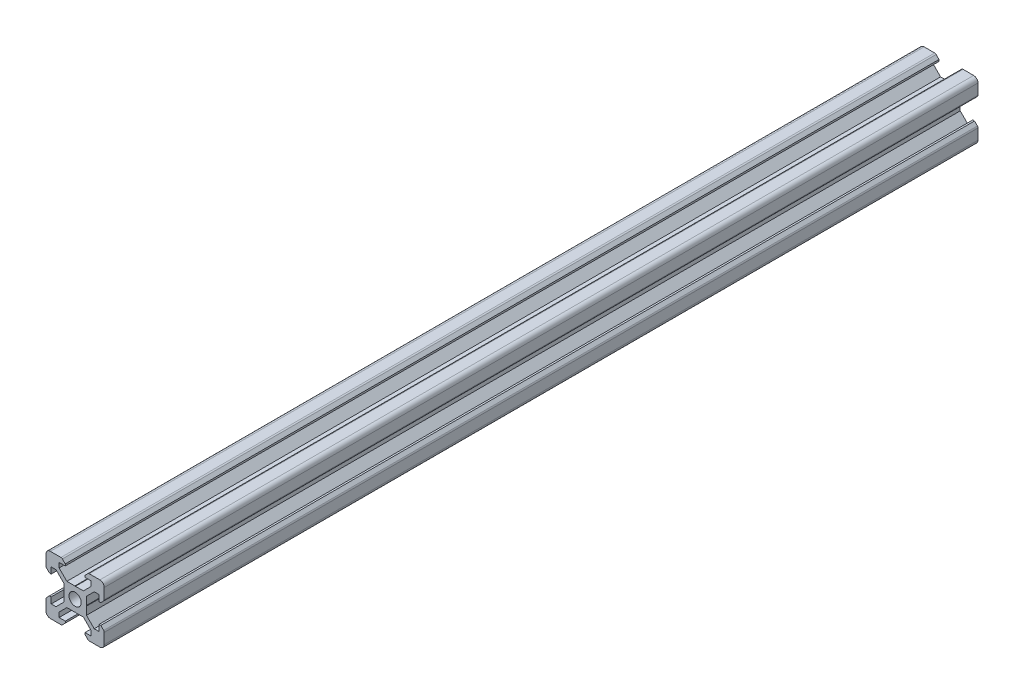
from build123d import *

# Parameters (mm, degrees)
SKETCH1_R           = 2.1
BOSS_EXTRUDE1_DEPTH = 300


with BuildPart() as part:
    # Sketch1 → Boss-Extrude1 (new body)
    with BuildSketch(Plane.XY):
        with BuildLine():
            Line((-8.5, 10), (-4.862792737, 10))
            ThreePointArc((-4.862792737, 10), (-4.598292737, 9.947387679), (-4.374060464, 9.797560464))
            Line((-4.374060464, 9.797560464), (-3.3865, 8.81))
            Line((-3.3865, 8.81), (-3.3865, 8.2))
            Line((-3.3865, 8.2), (-5.5, 8.2))
            Line((-5.5, 8.2), (-5.5, 6.561))
            Line((-5.5, 6.561), (-2.8395, 3.9005))
            Line((-2.8395, 3.9005), (-0.1, 3.9005))
            Line((-0.1, 3.9005), (0, 3.8005))
            Line((0, 3.8005), (0.1, 3.9005))
            Line((0.1, 3.9005), (2.8395, 3.9005))
            Line((2.8395, 3.9005), (5.5, 6.561))
            Line((5.5, 6.561), (5.5, 8.2))
            Line((5.5, 8.2), (3.3865, 8.2))
            Line((3.3865, 8.2), (3.3865, 8.81))
            Line((3.3865, 8.81), (4.374060464, 9.797560464))
            ThreePointArc((4.374060464, 9.797560464), (4.598292737, 9.947387679), (4.862792737, 10))
            Line((4.862792737, 10), (8.5, 10))
            ThreePointArc((8.5, 10), (9.560660172, 9.560660172), (10, 8.5))
            Line((10, 8.5), (10, 4.862792737))
            ThreePointArc((10, 4.862792737), (9.947387679, 4.598292737), (9.797560464, 4.374060464))
            Line((9.797560464, 4.374060464), (8.81, 3.3865))
            Line((8.81, 3.3865), (8.2, 3.3865))
            Line((8.2, 3.3865), (8.2, 5.5))
            Line((8.2, 5.5), (6.561, 5.5))
            Line((6.561, 5.5), (3.9005, 2.8395))
            Line((3.9005, 2.8395), (3.9005, 0.1))
            Line((3.9005, 0.1), (3.8005, 0))
            Line((3.8005, 0), (3.9005, -0.1))
            Line((3.9005, -0.1), (3.9005, -2.8395))
            Line((3.9005, -2.8395), (6.561, -5.5))
            Line((6.561, -5.5), (8.2, -5.5))
            Line((8.2, -5.5), (8.2, -3.3865))
            Line((8.2, -3.3865), (8.81, -3.3865))
            Line((8.81, -3.3865), (9.797560464, -4.374060464))
            ThreePointArc((9.797560464, -4.374060464), (9.947387679, -4.598292737), (10, -4.862792737))
            Line((10, -4.862792737), (10, -8.5))
            ThreePointArc((10, -8.5), (9.560660172, -9.560660172), (8.5, -10))
            Line((8.5, -10), (4.862792737, -10))
            ThreePointArc((4.862792737, -10), (4.598292737, -9.947387679), (4.374060464, -9.797560464))
            Line((4.374060464, -9.797560464), (3.3865, -8.81))
            Line((3.3865, -8.81), (3.3865, -8.2))
            Line((3.3865, -8.2), (5.5, -8.2))
            Line((5.5, -8.2), (5.5, -6.561))
            Line((5.5, -6.561), (2.8395, -3.9005))
            Line((2.8395, -3.9005), (0.1, -3.9005))
            Line((0.1, -3.9005), (0, -3.8005))
            Line((0, -3.8005), (-0.1, -3.9005))
            Line((-0.1, -3.9005), (-2.8395, -3.9005))
            Line((-2.8395, -3.9005), (-5.5, -6.561))
            Line((-5.5, -6.561), (-5.5, -8.2))
            Line((-5.5, -8.2), (-3.3865, -8.2))
            Line((-3.3865, -8.2), (-3.3865, -8.81))
            Line((-3.3865, -8.81), (-4.374060464, -9.797560464))
            ThreePointArc((-4.374060464, -9.797560464), (-4.598292737, -9.947387679), (-4.862792737, -10))
            Line((-4.862792737, -10), (-8.5, -10))
            ThreePointArc((-8.5, -10), (-9.560660172, -9.560660172), (-10, -8.5))
            Line((-10, -8.5), (-10, -4.862792737))
            ThreePointArc((-10, -4.862792737), (-9.947387679, -4.598292737), (-9.797560464, -4.374060464))
            Line((-9.797560464, -4.374060464), (-8.81, -3.3865))
            Line((-8.81, -3.3865), (-8.2, -3.3865))
            Line((-8.2, -3.3865), (-8.2, -5.5))
            Line((-8.2, -5.5), (-6.561, -5.5))
            Line((-6.561, -5.5), (-3.9005, -2.8395))
            Line((-3.9005, -2.8395), (-3.9005, -0.1))
            Line((-3.9005, -0.1), (-3.8005, 0))
            Line((-3.8005, 0), (-3.9005, 0.1))
            Line((-3.9005, 0.1), (-3.9005, 2.8395))
            Line((-3.9005, 2.8395), (-6.561, 5.5))
            Line((-6.561, 5.5), (-8.2, 5.5))
            Line((-8.2, 5.5), (-8.2, 3.3865))
            Line((-8.2, 3.3865), (-8.81, 3.3865))
            Line((-8.81, 3.3865), (-9.797560464, 4.374060464))
            ThreePointArc((-9.797560464, 4.374060464), (-9.947387679, 4.598292737), (-10, 4.862792737))
            Line((-10, 4.862792737), (-10, 8.5))
            ThreePointArc((-10, 8.5), (-9.560660172, 9.560660172), (-8.5, 10))
        make_face()
        Circle(SKETCH1_R, mode=Mode.SUBTRACT)
    extrude(amount=BOSS_EXTRUDE1_DEPTH)


solid = part.part
